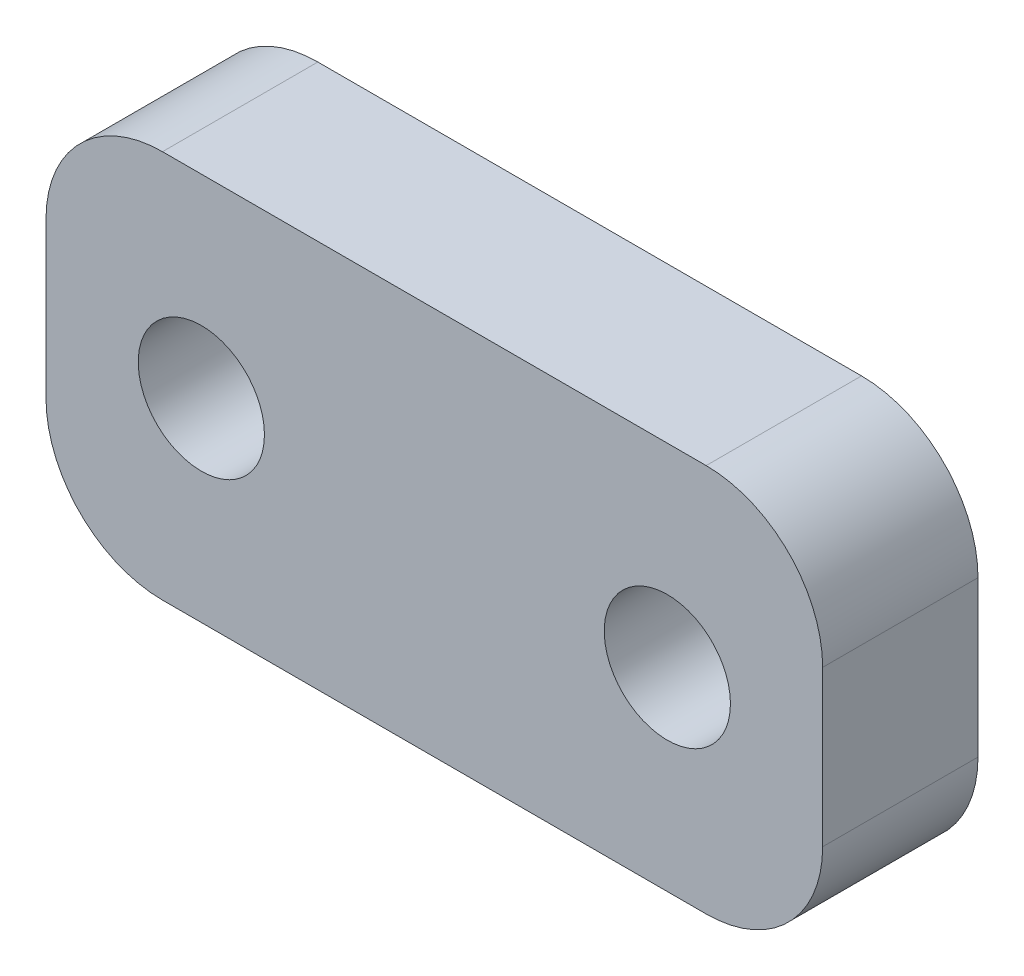
from build123d import *

# Parameters (mm, degrees)
CROQUIS1_W              = 20
CROQUIS1_H              = 10.000326638
CROQUIS1_R              = 1.625
SALIENTE_EXTRUIR1_DEPTH = 4
REDONDEO1_R             = 3


with BuildPart() as part:
    # Croquis1 → Saliente-Extruir1 (new body)
    with BuildSketch(Plane.XY):
        Rectangle(CROQUIS1_W, CROQUIS1_H)
        with Locations((-6, 0)):
            Circle(CROQUIS1_R, mode=Mode.SUBTRACT)
        with Locations((6, 0)):
            Circle(CROQUIS1_R, mode=Mode.SUBTRACT)
    extrude(amount=SALIENTE_EXTRUIR1_DEPTH)

    # Redondeo1
    redondeo1_edges = [part.edges().sort_by_distance(p)[0] for p in [
        (10, -5.000163319, 2),
        (-10, -5.000163319, 2),
        (-10, 5.000163319, 2),
        (10, 5.000163319, 2),
    ]]
    fillet(redondeo1_edges, radius=REDONDEO1_R)


solid = part.part
